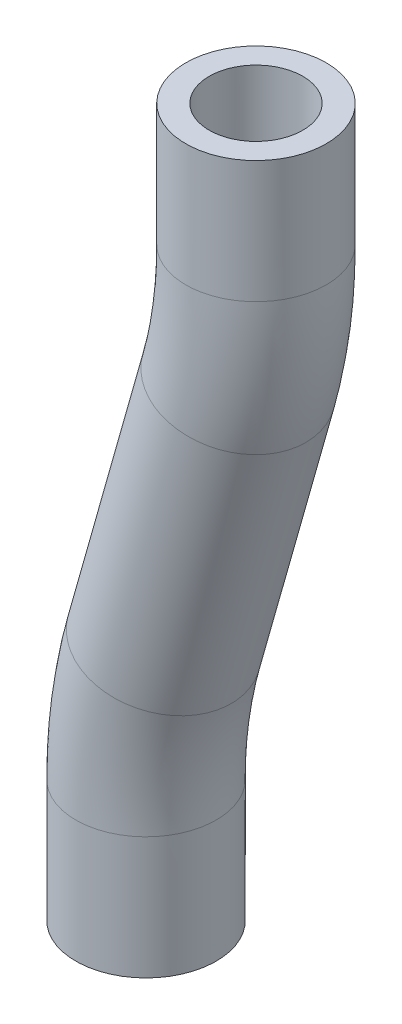
from build123d import *

# Parameters (mm, degrees)
SWEEP_THIN1_PROFILE_R   = 3
SWEEP_THIN1_PROFILE_R_2 = 2


with BuildPart() as part:
    # Sweep-Thin1: sweep along a path in Sketch1
    with BuildLine(Plane.XY) as sweep_thin1_path:
        Line((0, 0), (0, 5.22325087))
        ThreePointArc((0, 5.22325087), (0.190015729, 7.973618699), (0.75645232, 10.671725214))
        Line((0.75645232, 10.671725214), (3.94354768, 21.928274786))
        ThreePointArc((3.94354768, 21.928274786), (4.509984271, 24.626381301), (4.7, 27.37674913))
        Line((4.7, 27.37674913), (4.7, 32.6))
    # Sweep-Thin1 profile (on start of the path) → Sweep-Thin1 (sweep)
    with BuildSketch(Plane(origin=(0, 0, 0), x_dir=(1, 0, 0), z_dir=(0, 1, 0))):
        Circle(SWEEP_THIN1_PROFILE_R)
        Circle(SWEEP_THIN1_PROFILE_R_2, mode=Mode.SUBTRACT)
    sweep(path=sweep_thin1_path.line)


solid = part.part
